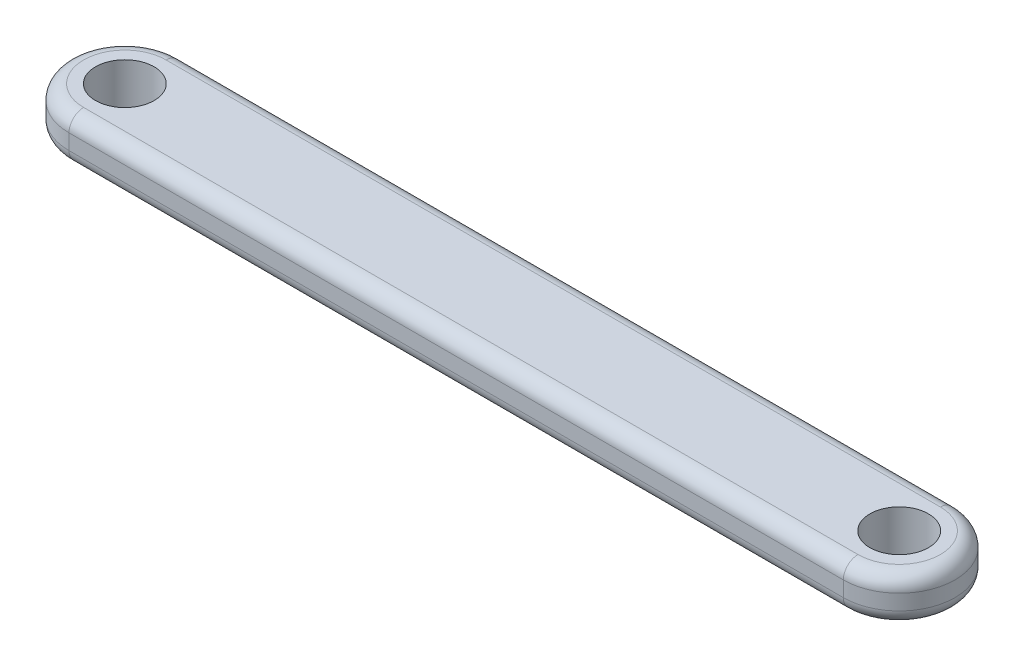
from build123d import *

# Parameters (mm, degrees)
SKETCH1_R           = 2
BOSS_EXTRUDE1_DEPTH = 1.524
FILLET1_R           = 1


with BuildPart() as part:
    # Sketch1 → Boss-Extrude1 (new body, symmetric)
    with BuildSketch(Plane(origin=(0, 0, 0), x_dir=(1, 0, 0), z_dir=(0, 1, 0))):
        with BuildLine():
            Line((-26.418872232, 3.81), (26.418872232, 3.81))
            ThreePointArc((26.418872232, 3.81), (30.228872232, 0), (26.418872232, -3.81))
            Line((26.418872232, -3.81), (-26.418872232, -3.81))
            ThreePointArc((-26.418872232, -3.81), (-30.228872232, 0), (-26.418872232, 3.81))
        make_face()
        with Locations((-26.418872232, 0)):
            Circle(SKETCH1_R, mode=Mode.SUBTRACT)
        with Locations((26.418872232, 0)):
            Circle(SKETCH1_R, mode=Mode.SUBTRACT)
    extrude(amount=BOSS_EXTRUDE1_DEPTH, both=True)

    # Fillet1
    fillet1_edges = [part.edges().sort_by_distance(p)[0] for p in [
        (30.228872232, 1.524, 0),
        (0, 1.524, -3.81),
        (-30.228872232, 1.524, 0),
        (0, -1.524, -3.81),
        (30.228872232, -1.524, 0),
        (0, -1.524, 3.81),
        (-30.228872232, -1.524, 0),
        (0, 1.524, 3.81),
    ]]
    fillet(fillet1_edges, radius=FILLET1_R)


solid = part.part
